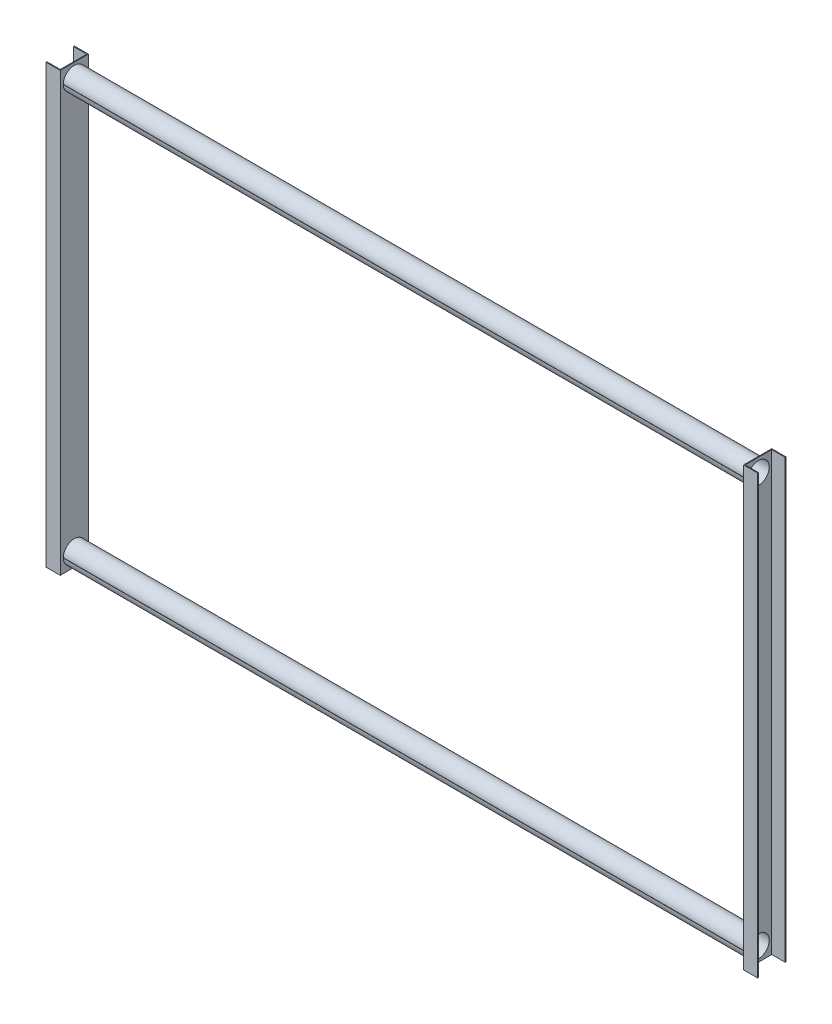
from build123d import *

# Parameters (mm, degrees)
BOSS_EXTRUDE1_DEPTH     = 1600
BOSS_EXTRUDE1_2_DEPTH   = 1600
SKETCH4_R               = 39.5
CUT_EXTRUDE2_DEPTH      = 2552.5
CUT_EXTRUDE2_DEPTH_BACK = 52.5
BOSS_EXTRUDE2_DEPTH     = 2500


with BuildPart() as part:
    # Sketch3 → Boss-Extrude1 (new body)
    with BuildSketch(Plane(origin=(0, 0, 0), x_dir=(1, 0, 0), z_dir=(0, 1, 0))):
        Polygon((-51.5, 51.5), (0, 51.5), (0, -51.5), (-51.5, -51.5), (-51.5, -48.5), (-3, -48.5), (-3, 48.5), (-51.5, 48.5), align=None)
    extrude(amount=BOSS_EXTRUDE1_DEPTH)


with BuildPart() as body_2:
    # Sketch3 → Boss-Extrude1 2 (new body)
    with BuildSketch(Plane(origin=(0, 0, 0), x_dir=(1, 0, 0), z_dir=(0, 1, 0))):
        Polygon((2503, 48.5), (2551.5, 48.5), (2551.5, 51.5), (2500, 51.5), (2500, -51.5), (2551.5, -51.5), (2551.5, -48.5), (2503, -48.5), align=None)
    extrude(amount=BOSS_EXTRUDE1_2_DEPTH)


with BuildPart() as cut_extrude2_tool:
    # Sketch4 → Cut-Extrude2 (new body, two sides)
    with BuildSketch(Plane(origin=(0, 0, 0), x_dir=(0, 0, -1), z_dir=(1, 0, 0))) as cut_extrude2_sk:
        with Locations((0, 1550)):
            Circle(SKETCH4_R)
        with Locations((0, 50)):
            Circle(SKETCH4_R)
    extrude(amount=CUT_EXTRUDE2_DEPTH)
    extrude(cut_extrude2_sk.sketch, amount=-CUT_EXTRUDE2_DEPTH_BACK)


with BuildPart() as part_1:
    add(part.part)

    # Cut-Extrude2: cut by cut_extrude2_tool
    add(cut_extrude2_tool.part, mode=Mode.SUBTRACT)



with BuildPart() as body_2_1:
    add(body_2.part)

    # Cut-Extrude2: cut by cut_extrude2_tool
    add(cut_extrude2_tool.part, mode=Mode.SUBTRACT)


with BuildPart() as part_2:
    add(part_1.part)

    add(body_2_1.part)  # Boss-Extrude2 merges body 2
    # Sketch5 → Boss-Extrude2 (add)
    with BuildSketch(Plane(origin=(0, 0, 0), x_dir=(0, 0, -1), z_dir=(1, 0, 0))):
        with BuildLine():
            Line((-39.496835316, 49.5), (-40.496913463, 49.5))
            ThreePointArc((-40.496913463, 49.5), (40.5, 50), (-40.496913463, 50.5))
            Line((-40.496913463, 50.5), (-39.496835316, 50.5))
            ThreePointArc((-39.496835316, 50.5), (39.5, 50), (-39.496835316, 49.5))
        make_face()
        with BuildLine():
            Line((-39.496835316, 1549.5), (-40.496913463, 1549.5))
            ThreePointArc((-40.496913463, 1549.5), (40.5, 1550), (-40.496913463, 1550.5))
            Line((-40.496913463, 1550.5), (-39.496835316, 1550.5))
            ThreePointArc((-39.496835316, 1550.5), (39.5, 1550), (-39.496835316, 1549.5))
        make_face()
    extrude(amount=BOSS_EXTRUDE2_DEPTH)


solid = part_2.part
